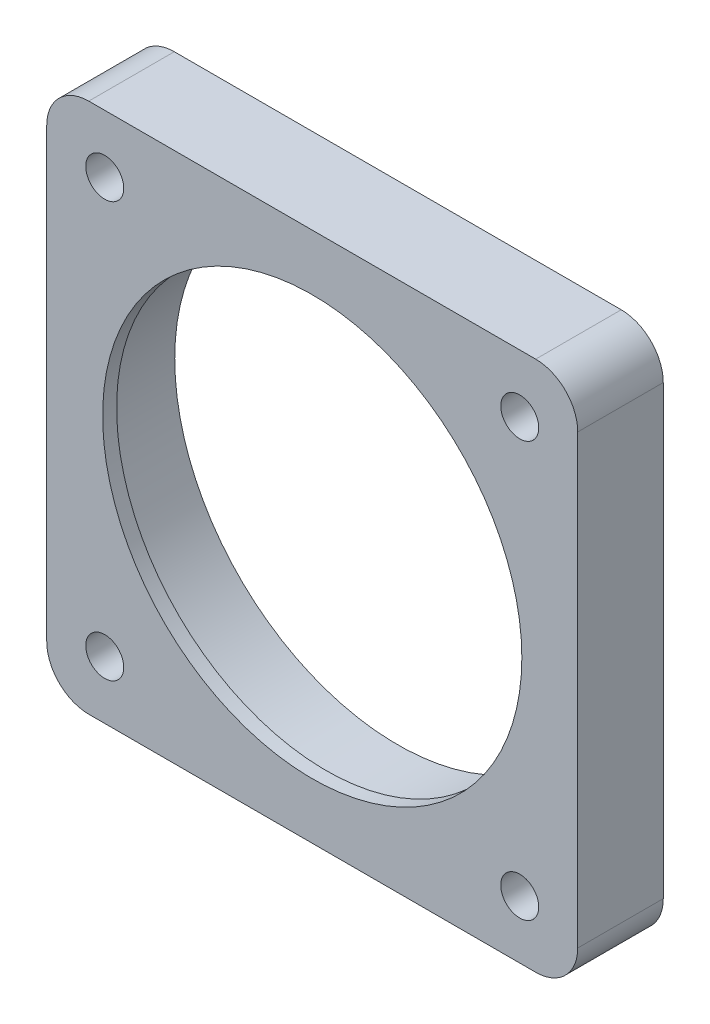
from build123d import *

# Parameters (mm, degrees)
SKETCH1_R               = 2.159
SKETCH1_R_2             = 28.5115
BOSS_EXTRUDE1_DEPTH     = 9.7155
SKETCH1_4_R             = 28.5115
SKETCH1_4_R_2           = 23.8125
FLUSH_BEZEL_DEPTH       = 9.7155
SKETCH1_5_R             = 28.5115
SKETCH1_5_R_2           = 23.8125
BOSS_EXTRUDE4_DEPTH     = 6.35
SKETCH2_R               = 25.3365
CUT_EXTRUDE1_DEPTH      = 7.35
CUT_EXTRUDE1_DEPTH_BACK = 9.7155
SKETCH3_R               = 28.5115
CUT_EXTRUDE2_DEPTH      = 7.35
SKETCH4_R               = 25.3365
SKETCH4_R_2             = 23.8125
BOSS_EXTRUDE7_DEPTH     = 1.5875


with BuildPart() as part:
    # Sketch1 → Boss-Extrude1 (new body)
    with BuildSketch(Plane.XY):
        with BuildLine():
            ThreePointArc((-24.49722379, -28.024879905), (-26.788104009, -26.788104009), (-28.024879905, -24.49722379))
            Line((-28.024879905, -24.49722379), (-30.1625, -14.199031657))
            Line((-30.1625, -14.199031657), (-30.1625, 14.199031657))
            Line((-30.1625, 14.199031657), (-28.024879905, 24.49722379))
            ThreePointArc((-28.024879905, 24.49722379), (-26.788104009, 26.788104009), (-24.49722379, 28.024879905))
            Line((-24.49722379, 28.024879905), (-14.199031657, 30.1625))
            Line((-14.199031657, 30.1625), (14.199031657, 30.1625))
            Line((14.199031657, 30.1625), (24.441349319, 28.268787691))
            ThreePointArc((24.441349319, 28.268787691), (26.949748619, 26.949748619), (28.268787691, 24.441349319))
            Line((28.268787691, 24.441349319), (30.1625, 14.199031657))
            Line((30.1625, 14.199031657), (30.1625, -14.199031657))
            Line((30.1625, -14.199031657), (28.024879905, -24.49722379))
            ThreePointArc((28.024879905, -24.49722379), (26.788104009, -26.788104009), (24.49722379, -28.024879905))
            Line((24.49722379, -28.024879905), (14.199031657, -30.1625))
            Line((14.199031657, -30.1625), (-14.199031657, -30.1625))
            Line((-14.199031657, -30.1625), (-24.49722379, -28.024879905))
        make_face()
        with Locations((-23.573172318, -23.573172318)):
            Circle(SKETCH1_R, mode=Mode.SUBTRACT)
        with Locations((23.573172318, -23.573172318)):
            Circle(SKETCH1_R, mode=Mode.SUBTRACT)
        with Locations((23.573172318, 23.573172318)):
            Circle(SKETCH1_R, mode=Mode.SUBTRACT)
        with Locations((-23.573172318, 23.573172318)):
            Circle(SKETCH1_R, mode=Mode.SUBTRACT)
        Circle(SKETCH1_R_2, mode=Mode.SUBTRACT)
        with BuildLine():
            Line((28.268787691, 24.441349319), (30.1625, 14.199031657))
            Line((30.1625, 14.199031657), (30.1625, 25.3873))
            ThreePointArc((30.1625, 25.3873), (28.763876302, 28.763876302), (25.3873, 30.1625))
            Line((25.3873, 30.1625), (14.199031657, 30.1625))
            Line((14.199031657, 30.1625), (24.441349319, 28.268787691))
            ThreePointArc((24.441349319, 28.268787691), (26.949748619, 26.949748619), (28.268787691, 24.441349319))
        make_face()
        with BuildLine():
            Line((-30.1625, 25.3873), (-30.1625, 14.199031657))
            Line((-30.1625, 14.199031657), (-28.024879905, 24.49722379))
            ThreePointArc((-28.024879905, 24.49722379), (-26.788104009, 26.788104009), (-24.49722379, 28.024879905))
            Line((-24.49722379, 28.024879905), (-14.199031657, 30.1625))
            Line((-14.199031657, 30.1625), (-25.3873, 30.1625))
            ThreePointArc((-25.3873, 30.1625), (-28.763876302, 28.763876302), (-30.1625, 25.3873))
        make_face()
        with BuildLine():
            Line((-25.3873, -30.1625), (-14.199031657, -30.1625))
            Line((-14.199031657, -30.1625), (-24.49722379, -28.024879905))
            ThreePointArc((-24.49722379, -28.024879905), (-26.788104009, -26.788104009), (-28.024879905, -24.49722379))
            Line((-28.024879905, -24.49722379), (-30.1625, -14.199031657))
            Line((-30.1625, -14.199031657), (-30.1625, -25.3873))
            ThreePointArc((-30.1625, -25.3873), (-28.763876302, -28.763876302), (-25.3873, -30.1625))
        make_face()
        with BuildLine():
            Line((24.49722379, -28.024879905), (14.199031657, -30.1625))
            Line((14.199031657, -30.1625), (25.3873, -30.1625))
            ThreePointArc((25.3873, -30.1625), (28.763876302, -28.763876302), (30.1625, -25.3873))
            Line((30.1625, -25.3873), (30.1625, -14.199031657))
            Line((30.1625, -14.199031657), (28.024879905, -24.49722379))
            ThreePointArc((28.024879905, -24.49722379), (26.788104009, -26.788104009), (24.49722379, -28.024879905))
        make_face()
    extrude(amount=BOSS_EXTRUDE1_DEPTH)

    # Sketch1_4 → Flush Bezel (add)
    with BuildSketch(Plane.XY):
        Circle(SKETCH1_4_R)
        Circle(SKETCH1_4_R_2, mode=Mode.SUBTRACT)
    extrude(amount=FLUSH_BEZEL_DEPTH)

    # Sketch1_5 → Boss-Extrude4 (add)
    with BuildSketch(Plane.XY):
        Circle(SKETCH1_5_R)
        Circle(SKETCH1_5_R_2, mode=Mode.SUBTRACT)
    extrude(amount=-BOSS_EXTRUDE4_DEPTH)

    # Sketch2 → Cut-Extrude1 (cut, two sides)
    with BuildSketch(Plane(origin=(0, 0, 0), x_dir=(-1, 0, 0), z_dir=(0, 0, -1))) as cut_extrude1_sk:
        Circle(SKETCH2_R)
    extrude(amount=CUT_EXTRUDE1_DEPTH, mode=Mode.SUBTRACT)
    extrude(cut_extrude1_sk.sketch, amount=-CUT_EXTRUDE1_DEPTH_BACK, mode=Mode.SUBTRACT)

    # Sketch3 → Cut-Extrude2 (cut, through all)
    with BuildSketch(Plane(origin=(0, 0, 0), x_dir=(-1, 0, 0), z_dir=(0, 0, -1))):
        Circle(SKETCH3_R)
    extrude(amount=CUT_EXTRUDE2_DEPTH, mode=Mode.SUBTRACT)

    # Sketch4 → Boss-Extrude7 (add)
    with BuildSketch(Plane.XY.offset(9.7155)):
        Circle(SKETCH4_R)
        Circle(SKETCH4_R_2, mode=Mode.SUBTRACT)
    extrude(amount=-BOSS_EXTRUDE7_DEPTH)


solid = part.part
